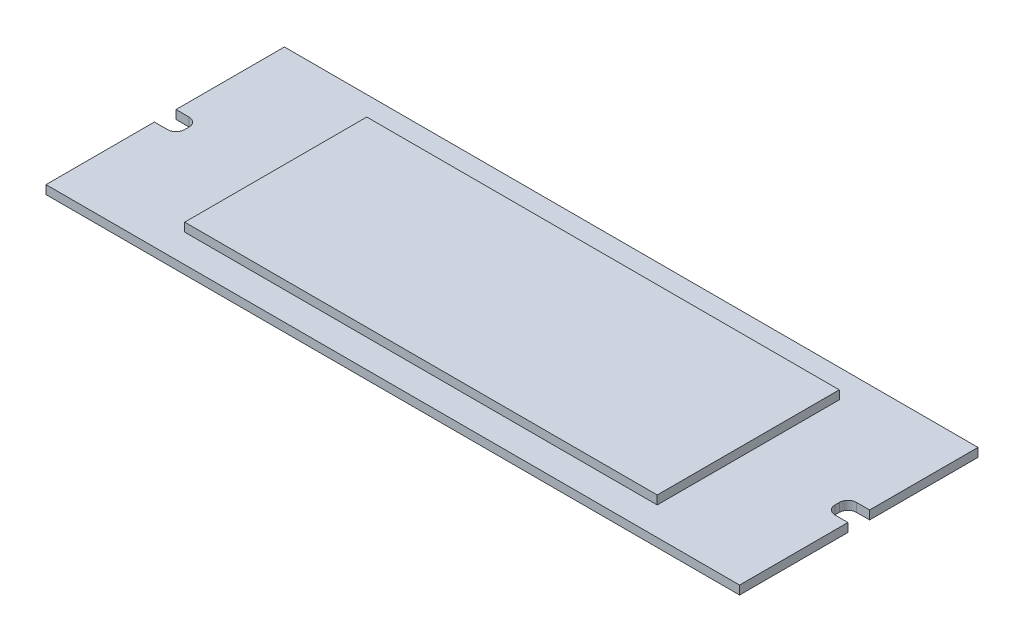
from build123d import *

# Parameters (mm, degrees)
SKETCH1_W           = 160
SKETCH1_H           = 55
BOSS_EXTRUDE1_DEPTH = 2
SKETCH2_W           = 109
SKETCH2_H           = 42
BOSS_EXTRUDE2_DEPTH = 2
CUT_EXTRUDE1_DEPTH  = 2


with BuildPart() as part:
    # Sketch1 → Boss-Extrude1 (new body)
    with BuildSketch(Plane(origin=(0, 0, 0), x_dir=(1, 0, 0), z_dir=(0, 1, 0))):
        with Locations((21.028856201, -0.390930324)):
            Rectangle(SKETCH1_W, SKETCH1_H)
    extrude(amount=BOSS_EXTRUDE1_DEPTH)

    # Sketch2 → Boss-Extrude2 (add)
    with BuildSketch(Plane(origin=(0, 2, 0), x_dir=(1, 0, 0), z_dir=(0, 1, 0))):
        with Locations((21.028856201, -0.390930324)):
            Rectangle(SKETCH2_W, SKETCH2_H)
    extrude(amount=BOSS_EXTRUDE2_DEPTH)

    # Sketch3 → Cut-Extrude1 (cut)
    with BuildSketch(Plane(origin=(0, 2, 0), x_dir=(1, 0, 0), z_dir=(0, 1, 0))):
        with BuildLine():
            Line((-58.971143799, 2.109069676), (-55.971143799, 2.109069676))
            ThreePointArc((-55.971143799, 2.109069676), (-54.556930237, 1.523283239), (-53.971143799, 0.109069676))
            Line((-53.971143799, 0.109069676), (-53.971143799, -0.890930324))
            ThreePointArc((-53.971143799, -0.890930324), (-54.556930237, -2.305143886), (-55.971143799, -2.890930324))
            Line((-55.971143799, -2.890930324), (-58.971143799, -2.890930324))
            Line((-58.971143799, -2.890930324), (-58.971143799, 2.109069676))
        make_face()
        with BuildLine():
            Line((101.028856201, 2.109069676), (98.028856201, 2.109069676))
            ThreePointArc((98.028856201, 2.109069676), (96.614642638, 1.523283239), (96.028856201, 0.109069676))
            Line((96.028856201, 0.109069676), (96.028856201, -0.890930324))
            ThreePointArc((96.028856201, -0.890930324), (96.614642638, -2.305143886), (98.028856201, -2.890930324))
            Line((98.028856201, -2.890930324), (101.028856201, -2.890930324))
            Line((101.028856201, -2.890930324), (101.028856201, 2.109069676))
        make_face()
    extrude(amount=-CUT_EXTRUDE1_DEPTH, mode=Mode.SUBTRACT)


solid = part.part
